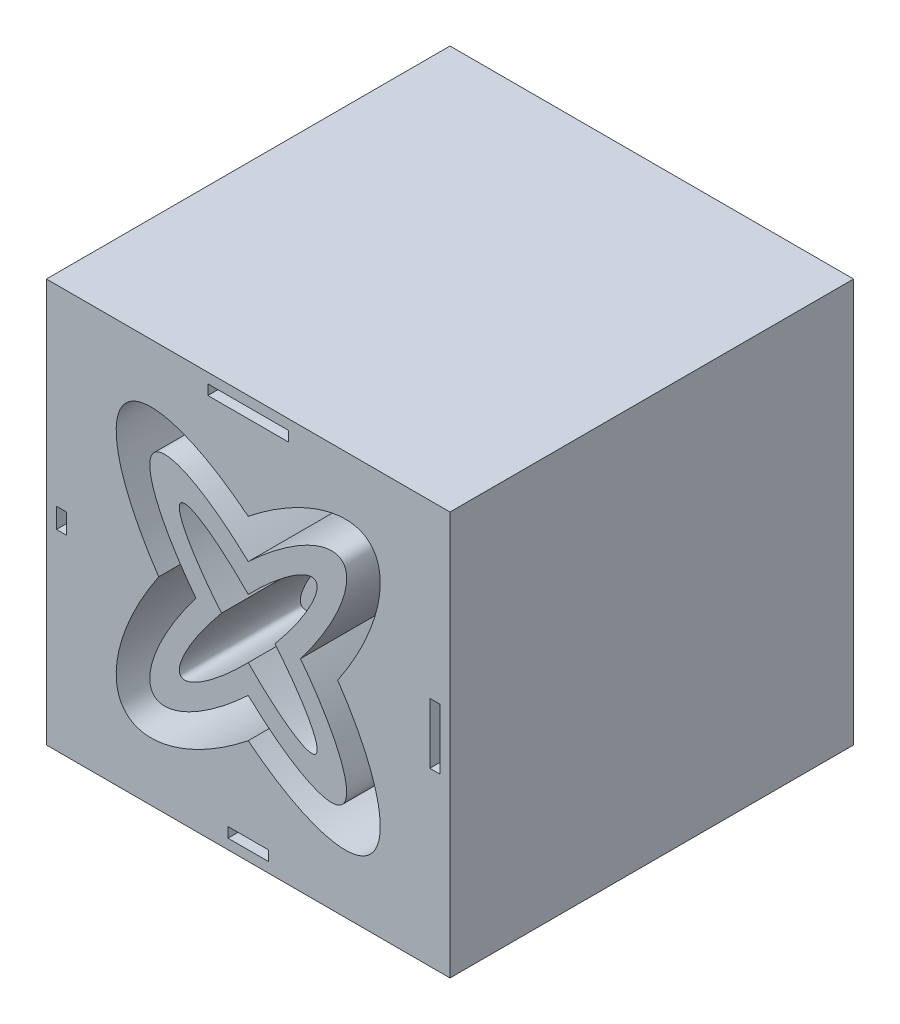
from build123d import *

# Parameters (mm, degrees)
BOSS_EXTRU_1_DEPTH      = 100
BOSS_EXTRU_1_DEPTH_BACK = 100
ESQUISSE1_W             = 200
ESQUISSE1_H             = 200
ESQUISSE2_W             = 20
ESQUISSE2_H             = 5
ESQUISSE2_W_2           = 5
ESQUISSE2_H_2           = 30
ESQUISSE2_W_3           = 40
ESQUISSE2_H_3           = 10
ENL_V_MAT_EXTRU_2_DEPTH = 60
ECHELLE1_SCALE          = 0.001


with BuildPart() as part:
    # Esquisse1 → Boss.-Extru.1 (new, two sides: drawn at the far end of the back side and taken through both)
    with BuildSketch(Plane.XY.offset(-BOSS_EXTRU_1_DEPTH_BACK)):
        Rectangle(ESQUISSE1_W, ESQUISSE1_H)
    extrude(amount=BOSS_EXTRU_1_DEPTH + BOSS_EXTRU_1_DEPTH_BACK)

    # Esquisse2 → Enlèv. mat.-Extru.2 (cut)
    # profile 1 of 6: a face of its own
    with BuildSketch(Plane.XY.offset(100)):
        with Locations((0, -92.5)):
            Rectangle(ESQUISSE2_W, ESQUISSE2_H)
    # profile 2 of 6: a face of its own
    with BuildSketch(Plane.XY.offset(100)):
        with Locations((92.5, 0)):
            Rectangle(ESQUISSE2_W_2, ESQUISSE2_H_2)
    # profile 3 of 6: a face of its own
    with BuildSketch(Plane.XY.offset(100)):
        with Locations((0, 92.5)):
            Rectangle(ESQUISSE2_W_3, ESQUISSE2_H)
    # profile 4 of 6: a face of its own
    with BuildSketch(Plane.XY.offset(100)):
        with Locations((-92.5, 0)):
            Rectangle(ESQUISSE2_W_2, ESQUISSE2_H_3)
    # profile 5 of 6: a face of its own
    with BuildSketch(Plane.XY.offset(100)):
        with BuildLine():
            add(Edge.make_bspline(
                [(44.351047547, 0), (78.546468568, 50.493573541), (60, 67.082039325)],
                knots=[5.047131803, 5.047131803, 5.047131803, 6.283185307, 6.283185307, 6.283185307], degree=2, weights=[1, 0.815023398, 1]))
            add(Edge.make_bspline(
                [(60, 67.082039325), (42.895976585, 82.380342943), (0, 48.1460303)],
                knots=[0, 0, 0, 1.160661933, 1.160661933, 1.160661933], degree=2, weights=[1, 0.836281227, 1]))
            add(Edge.make_bspline(
                [(0, 48.1460303), (-167.470598231, 181.800542326), (-44.351047547, 0)],
                knots=[1.980930721, 1.980930721, 1.980930721, 4.377646158, 4.377646158, 4.377646158], degree=2, weights=[1, 0.363887936, 1]))
            add(Edge.make_bspline(
                [(-44.351047547, 0), (-167.470598231, -181.800542326), (0, -48.1460303)],
                knots=[1.90553915, 1.90553915, 1.90553915, 4.302254586, 4.302254586, 4.302254586], degree=2, weights=[1, 0.363887936, 1]))
            add(Edge.make_bspline(
                [(0, -48.1460303), (42.895976585, -82.380342943), (60, -67.082039325)],
                knots=[5.122523374, 5.122523374, 5.122523374, 6.283185307, 6.283185307, 6.283185307], degree=2, weights=[1, 0.836281227, 1]))
            add(Edge.make_bspline(
                [(60, -67.082039325), (78.546468568, -50.493573541), (44.351047547, 0)],
                knots=[0, 0, 0, 1.236053504, 1.236053504, 1.236053504], degree=2, weights=[1, 0.815023398, 1]))
        make_face()
        with BuildLine():
            add(Edge.make_bspline(
                [(34.963798186, 12.790653527), (55.451983981, 44.389377301), (46.444423692, 52.376722227)],
                knots=[5.199511364, 5.199511364, 5.199511364, 6.283185307, 6.283185307, 6.283185307], degree=2, weights=[1, 0.856762781, 1]))
            add(Edge.make_bspline(
                [(25.904343593, -0.010581385), (30.873554366, 6.482311445), (34.963798186, 12.790653527)],
                knots=[4.960320969, 4.960320969, 4.960320969, 5.199511364, 5.199511364, 5.199511364], degree=2, weights=[1, 0.992857014, 1]))
            add(Edge.make_bspline(
                [(34.947788151, -12.810877359), (30.864821234, -6.503174511), (25.904343593, -0.010581385)],
                knots=[1.08384718, 1.08384718, 1.08384718, 1.322872375, 1.322872375, 1.322872375], degree=2, weights=[1, 0.992866866, 1]))
            add(Edge.make_bspline(
                [(46.401774484, -52.416151598), (55.417806713, -44.434644344), (34.947788151, -12.810877359)],
                knots=[0, 0, 0, 1.08384718, 1.08384718, 1.08384718], degree=2, weights=[1, 0.856718108, 1]))
            add(Edge.make_bspline(
                [(11.215237905, -38.482756231), (37.960842812, -59.888546956), (46.401774484, -52.416151598)],
                knots=[5.256667724, 5.256667724, 5.256667724, 6.283185307, 6.283185307, 6.283185307], degree=2, weights=[1, 0.871149008, 1]))
            add(Edge.make_bspline(
                [(-0.012056803, -28.704168287), (5.6778729, -34.050937364), (11.215237905, -38.482756231)],
                knots=[5.02432639, 5.02432639, 5.02432639, 5.256667724, 5.256667724, 5.256667724], degree=2, weights=[1, 0.993259773, 1]))
            add(Edge.make_bspline(
                [(-11.235615159, -38.46388206), (-5.70025818, -34.040397845), (-0.012056803, -28.704168287)],
                knots=[4.168346861, 4.168346861, 4.168346861, 4.400442895, 4.400442895, 4.400442895], degree=2, weights=[1, 0.993273982, 1]))
            add(Edge.make_bspline(
                [(-34.963798186, -12.790653527), (-95.025359829, -105.422998569), (-11.235615159, -38.46388206)],
                knots=[2.05791871, 2.05791871, 2.05791871, 4.168346861, 4.168346861, 4.168346861], degree=2, weights=[1, 0.493041495, 1]))
            add(Edge.make_bspline(
                [(-25.904343593, 0.010581385), (-30.873554366, -6.482311445), (-34.963798186, -12.790653527)],
                knots=[1.818728315, 1.818728315, 1.818728315, 2.05791871, 2.05791871, 2.05791871], degree=2, weights=[1, 0.992857014, 1]))
            add(Edge.make_bspline(
                [(-34.947788151, 12.810877359), (-30.864821234, 6.503174511), (-25.904343593, 0.010581385)],
                knots=[4.225439834, 4.225439834, 4.225439834, 4.464465029, 4.464465029, 4.464465029], degree=2, weights=[1, 0.992866866, 1]))
            add(Edge.make_bspline(
                [(-11.215237905, 38.482756231), (-94.939897106, 105.491617671), (-34.947788151, 12.810877359)],
                knots=[2.115075071, 2.115075071, 2.115075071, 4.225439834, 4.225439834, 4.225439834], degree=2, weights=[1, 0.493069068, 1]))
            add(Edge.make_bspline(
                [(0.012056803, 28.704168287), (-5.6778729, 34.050937364), (-11.215237905, 38.482756231)],
                knots=[1.882733737, 1.882733737, 1.882733737, 2.115075071, 2.115075071, 2.115075071], degree=2, weights=[1, 0.993259773, 1]))
            add(Edge.make_bspline(
                [(11.235615159, 38.46388206), (5.70025818, 34.040397845), (0.012056803, 28.704168287)],
                knots=[1.026754208, 1.026754208, 1.026754208, 1.258850242, 1.258850242, 1.258850242], degree=2, weights=[1, 0.993273982, 1]))
            add(Edge.make_bspline(
                [(46.444423692, 52.376722227), (38.007437164, 59.858117784), (11.235615159, 38.46388206)],
                knots=[0, 0, 0, 1.026754208, 1.026754208, 1.026754208], degree=2, weights=[1, 0.871090909, 1]))
        make_face(mode=Mode.SUBTRACT)
    # profile 6 of 6: a face of its own
    with BuildSketch(Plane.XY.offset(100)):
        with BuildLine():
            add(Edge.make_bspline(
                [(-7.175653735, 21.648232182), (-13.332416809, 27.374863299), (-18.612839117, 31.302142581)],
                knots=[5.143999994, 5.143999994, 5.143999994, 5.508590295, 5.508590295, 5.508590295], degree=2, weights=[1, 0.983430202, 1]))
            add(Edge.make_bspline(
                [(-18.612839117, 31.302142581), (-30.297014822, 39.992171236), (-33.337584051, 37.272607484)],
                knots=[5.508590295, 5.508590295, 5.508590295, 6.283185307, 6.283185307, 6.283185307], degree=2, weights=[1, 0.925933138, 1]))
            add(Edge.make_bspline(
                [(-33.337584051, 37.272607484), (-36.545170088, 34.40365958), (-28.333577614, 20.784685634)],
                knots=[0, 0, 0, 0.812710828, 0.812710828, 0.812710828], degree=2, weights=[1, 0.918567495, 1]))
            add(Edge.make_bspline(
                [(-28.333577614, 20.784685634), (-24.769964796, 14.874413017), (-19.537000987, 7.961691819)],
                knots=[0.812710828, 0.812710828, 0.812710828, 1.181939924, 1.181939924, 1.181939924], degree=2, weights=[1, 0.98300708, 1]))
            add(Edge.make_bspline(
                [(-19.537000987, 7.961691819), (-16.557240721, 4.025442169), (-13.207242339, -0.000820796)],
                knots=[1.181939924, 1.181939924, 1.181939924, 1.39381223, 1.39381223, 1.39381223], degree=2, weights=[1, 0.994394011, 1]))
            add(Edge.make_bspline(
                [(-13.207242339, -0.000820796), (-16.554757633, -4.02487595), (-19.532518746, -7.959034608)],
                knots=[4.889386694, 4.889386694, 4.889386694, 5.101135905, 5.101135905, 5.101135905], degree=2, weights=[1, 0.994400517, 1]))
            add(Edge.make_bspline(
                [(-19.532518746, -7.959034608), (-24.767080091, -14.874832768), (-28.331223599, -20.787396561)],
                knots=[5.101135905, 5.101135905, 5.101135905, 5.470506082, 5.470506082, 5.470506082], degree=2, weights=[1, 0.982994129, 1]))
            add(Edge.make_bspline(
                [(-28.331223599, -20.787396561), (-36.540472337, -34.405733401), (-33.332848981, -37.274185731)],
                knots=[5.470506082, 5.470506082, 5.470506082, 6.283185307, 6.283185307, 6.283185307], degree=2, weights=[1, 0.91857374, 1]))
            add(Edge.make_bspline(
                [(-33.332848981, -37.274185731), (-30.292388556, -39.993150779), (-18.610989061, -31.30402305)],
                knots=[0, 0, 0, 0.774531408, 0.774531408, 0.774531408], degree=2, weights=[1, 0.925945149, 1]))
            add(Edge.make_bspline(
                [(-18.610989061, -31.30402305), (-13.333864533, -27.378670689), (-7.181114109, -21.655379483)],
                knots=[0.774531408, 0.774531408, 0.774531408, 1.138951297, 1.138951297, 1.138951297], degree=2, weights=[1, 0.983445645, 1]))
            add(Edge.make_bspline(
                [(-7.181114109, -21.655379483), (-3.630901941, -18.35297053), (0.000474515, -14.64030379)],
                knots=[1.138951297, 1.138951297, 1.138951297, 1.350788667, 1.350788667, 1.350788667], degree=2, weights=[1, 0.994395858, 1]))
            add(Edge.make_bspline(
                [(0.000474515, -14.64030379), (3.628536023, -18.348927918), (7.175653735, -21.648232182)],
                knots=[1.790789772, 1.790789772, 1.790789772, 2.00240734, 2.00240734, 2.00240734], degree=2, weights=[1, 0.994407471, 1]))
            add(Edge.make_bspline(
                [(7.175653735, -21.648232182), (13.332416809, -27.374863299), (18.612839117, -31.302142581)],
                knots=[2.00240734, 2.00240734, 2.00240734, 2.366997642, 2.366997642, 2.366997642], degree=2, weights=[1, 0.983430202, 1]))
            add(Edge.make_bspline(
                [(18.612839117, -31.302142581), (47.73445351, -52.961151308), (28.333577614, -20.784685634)],
                knots=[2.366997642, 2.366997642, 2.366997642, 3.954303481, 3.954303481, 3.954303481], degree=2, weights=[1, 0.701245762, 1]))
            add(Edge.make_bspline(
                [(28.333577614, -20.784685634), (24.769964796, -14.874413017), (19.537000987, -7.961691819)],
                knots=[3.954303481, 3.954303481, 3.954303481, 4.323532577, 4.323532577, 4.323532577], degree=2, weights=[1, 0.98300708, 1]))
            add(Edge.make_bspline(
                [(19.537000987, -7.961691819), (16.557240721, -4.025442169), (13.207242339, 0.000820796)],
                knots=[4.323532577, 4.323532577, 4.323532577, 4.535404884, 4.535404884, 4.535404884], degree=2, weights=[1, 0.994394011, 1]))
            add(Edge.make_bspline(
                [(13.207242339, 0.000820796), (16.554757633, 4.02487595), (19.532518746, 7.959034608)],
                knots=[1.747794041, 1.747794041, 1.747794041, 1.959543251, 1.959543251, 1.959543251], degree=2, weights=[1, 0.994400517, 1]))
            add(Edge.make_bspline(
                [(19.532518746, 7.959034608), (24.767080091, 14.874832768), (28.331223599, 20.787396561)],
                knots=[1.959543251, 1.959543251, 1.959543251, 2.328913428, 2.328913428, 2.328913428], degree=2, weights=[1, 0.982994129, 1]))
            add(Edge.make_bspline(
                [(28.331223599, 20.787396561), (47.725559456, 52.960693645), (18.610989061, 31.30402305)],
                knots=[2.328913428, 2.328913428, 2.328913428, 3.916124062, 3.916124062, 3.916124062], degree=2, weights=[1, 0.701279698, 1]))
            add(Edge.make_bspline(
                [(18.610989061, 31.30402305), (13.333864533, 27.378670689), (7.181114109, 21.655379483)],
                knots=[3.916124062, 3.916124062, 3.916124062, 4.280543951, 4.280543951, 4.280543951], degree=2, weights=[1, 0.983445645, 1]))
            add(Edge.make_bspline(
                [(7.181114109, 21.655379483), (3.630901941, 18.35297053), (-0.000474515, 14.64030379)],
                knots=[4.280543951, 4.280543951, 4.280543951, 4.492381321, 4.492381321, 4.492381321], degree=2, weights=[1, 0.994395858, 1]))
            add(Edge.make_bspline(
                [(-0.000474515, 14.64030379), (-3.628536023, 18.348927918), (-7.175653735, 21.648232182)],
                knots=[4.932382425, 4.932382425, 4.932382425, 5.143999994, 5.143999994, 5.143999994], degree=2, weights=[1, 0.994407471, 1]))
        make_face()
    enl_v_mat_extru_2 = extrude(amount=-ENL_V_MAT_EXTRU_2_DEPTH, mode=Mode.SUBTRACT)

    # Symétrie2: Enlèv. mat.-Extru.2 across plane
    add(enl_v_mat_extru_2.mirror(Plane.XY), mode=Mode.SUBTRACT)


with BuildPart() as part_1:
    # Echelle1: scaled about (-0.166506621, -0.166511753, 0)
    add(part.part.scale(ECHELLE1_SCALE).moved(Location((-0.166340114, -0.166345241, 0))))


solid = part_1.part
